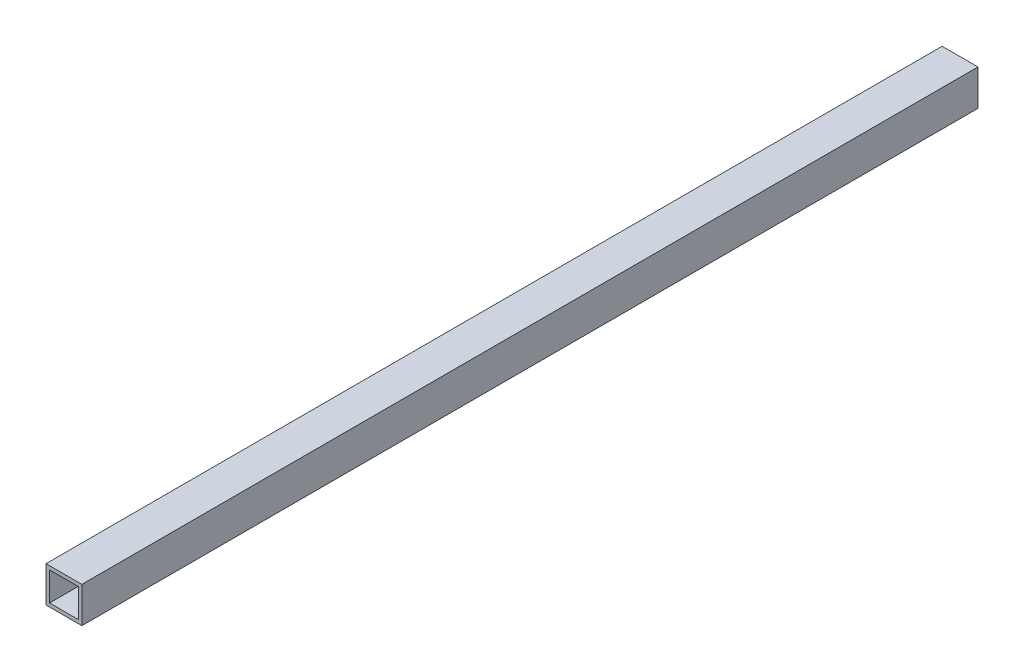
from build123d import *

# Parameters (mm, degrees)
IZIM1_W                     = 40
IZIM1_H                     = 40
IZIM1_W_2                   = 32
IZIM1_H_2                   = 32
Y_KSEKLIK_EKSTR_ZYON1_DEPTH = 1000


with BuildPart() as part:
    # Çizim1 → Yükseklik-Ekstrüzyon1 (new body)
    with BuildSketch(Plane.XY):
        with Locations((20, 20)):
            Rectangle(IZIM1_W, IZIM1_H)
        with Locations((20, 20)):
            Rectangle(IZIM1_W_2, IZIM1_H_2, mode=Mode.SUBTRACT)
    extrude(amount=-Y_KSEKLIK_EKSTR_ZYON1_DEPTH)


solid = part.part
